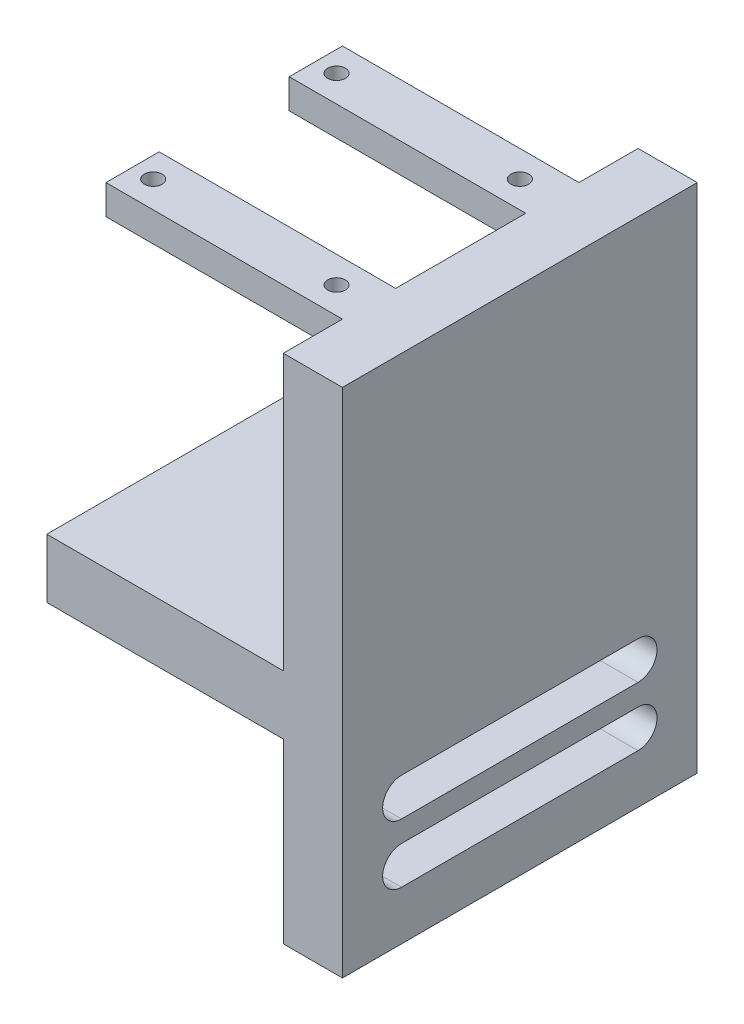
from build123d import *

# Parameters (mm, degrees)
SKETCH1_W           = 60
SKETCH1_H           = 56.5
SKETCH1_H_2         = 30
BOSS_EXTRUDE1_DEPTH = 10
SKETCH3_W           = 60
SKETCH3_H           = 10
BOSS_EXTRUDE2_DEPTH = 40
SKETCH4_W           = 9
SKETCH4_H           = 5
BOSS_EXTRUDE3_DEPTH = 40
CUT_EXTRUDE1_REACH  = 88.5
SKETCH5_R           = 1.5


with BuildPart() as part:
    # Sketch1 → Boss-Extrude1 (new body)
    with BuildSketch(Plane(origin=(0, 0, 0), x_dir=(0, 0, -1), z_dir=(1, 0, 0))):
        with Locations((0, 28.25)):
            Rectangle(SKETCH1_W, SKETCH1_H)
        with Locations((0, -15)):
            Rectangle(SKETCH1_W, SKETCH1_H_2)
        with BuildLine():
            ThreePointArc((-20, -21.7), (-23.2, -18.5), (-20, -15.3))
            Line((-20, -15.3), (20, -15.3))
            ThreePointArc((20, -15.3), (22.2627417, -16.2372583), (23.2, -18.5))
            ThreePointArc((23.2, -18.5), (22.2627417, -20.7627417), (20, -21.7))
            Line((20, -21.7), (-20, -21.7))
        make_face(mode=Mode.SUBTRACT)
        with BuildLine():
            ThreePointArc((-20, -11.7), (-23.2, -8.5), (-20, -5.3))
            Line((-20, -5.3), (20, -5.3))
            ThreePointArc((20, -5.3), (22.2627417, -6.2372583), (23.2, -8.5))
            ThreePointArc((23.2, -8.5), (22.2627417, -10.7627417), (20, -11.7))
            Line((20, -11.7), (-20, -11.7))
        make_face(mode=Mode.SUBTRACT)
    extrude(amount=BOSS_EXTRUDE1_DEPTH)

    # Sketch3 → Boss-Extrude2 (add)
    with BuildSketch(Plane.ZY):
        with Locations((0, 5)):
            Rectangle(SKETCH3_W, SKETCH3_H)
    extrude(amount=BOSS_EXTRUDE2_DEPTH)

    # Sketch4 → Boss-Extrude3 (add)
    with BuildSketch(Plane.ZY):
        with Locations((-15.5, 54)):
            Rectangle(SKETCH4_W, SKETCH4_H)
        with Locations((15.5, 54)):
            Rectangle(SKETCH4_W, SKETCH4_H)
    extrude(amount=BOSS_EXTRUDE3_DEPTH)

    # Sketch5 → Cut-Extrude1 (cut, up to next)
    with BuildSketch(Plane(origin=(0, 56.5, 0), x_dir=(1, 0, 0), z_dir=(0, 1, 0)), mode=Mode.PRIVATE) as cut_extrude1_sk1:
        with Locations((-5.5, 15.5)):
            Circle(SKETCH5_R)
    cut_extrude1_tool1 = extrude(cut_extrude1_sk1.sketch, amount=-CUT_EXTRUDE1_REACH, mode=Mode.PRIVATE) & part.part
    add(cut_extrude1_tool1.solids().sort_by_distance((-5.5, 56.5, -15.5))[0], mode=Mode.SUBTRACT)
    # Sketch5 → Cut-Extrude1 (cut, up to next)
    with BuildSketch(Plane(origin=(0, 56.5, 0), x_dir=(1, 0, 0), z_dir=(0, 1, 0)), mode=Mode.PRIVATE) as cut_extrude1_sk2:
        with Locations((-36.5, 15.5)):
            Circle(SKETCH5_R)
    cut_extrude1_tool2 = extrude(cut_extrude1_sk2.sketch, amount=-CUT_EXTRUDE1_REACH, mode=Mode.PRIVATE) & part.part
    add(cut_extrude1_tool2.solids().sort_by_distance((-36.5, 56.5, -15.5))[0], mode=Mode.SUBTRACT)
    # Sketch5 → Cut-Extrude1 (cut, up to next)
    with BuildSketch(Plane(origin=(0, 56.5, 0), x_dir=(1, 0, 0), z_dir=(0, 1, 0)), mode=Mode.PRIVATE) as cut_extrude1_sk3:
        with Locations((-5.5, -15.5)):
            Circle(SKETCH5_R)
    cut_extrude1_tool3 = extrude(cut_extrude1_sk3.sketch, amount=-CUT_EXTRUDE1_REACH, mode=Mode.PRIVATE) & part.part
    add(cut_extrude1_tool3.solids().sort_by_distance((-5.5, 56.5, 15.5))[0], mode=Mode.SUBTRACT)
    # Sketch5 → Cut-Extrude1 (cut, up to next)
    with BuildSketch(Plane(origin=(0, 56.5, 0), x_dir=(1, 0, 0), z_dir=(0, 1, 0)), mode=Mode.PRIVATE) as cut_extrude1_sk4:
        with Locations((-36.5, -15.5)):
            Circle(SKETCH5_R)
    cut_extrude1_tool4 = extrude(cut_extrude1_sk4.sketch, amount=-CUT_EXTRUDE1_REACH, mode=Mode.PRIVATE) & part.part
    add(cut_extrude1_tool4.solids().sort_by_distance((-36.5, 56.5, 15.5))[0], mode=Mode.SUBTRACT)


solid = part.part
